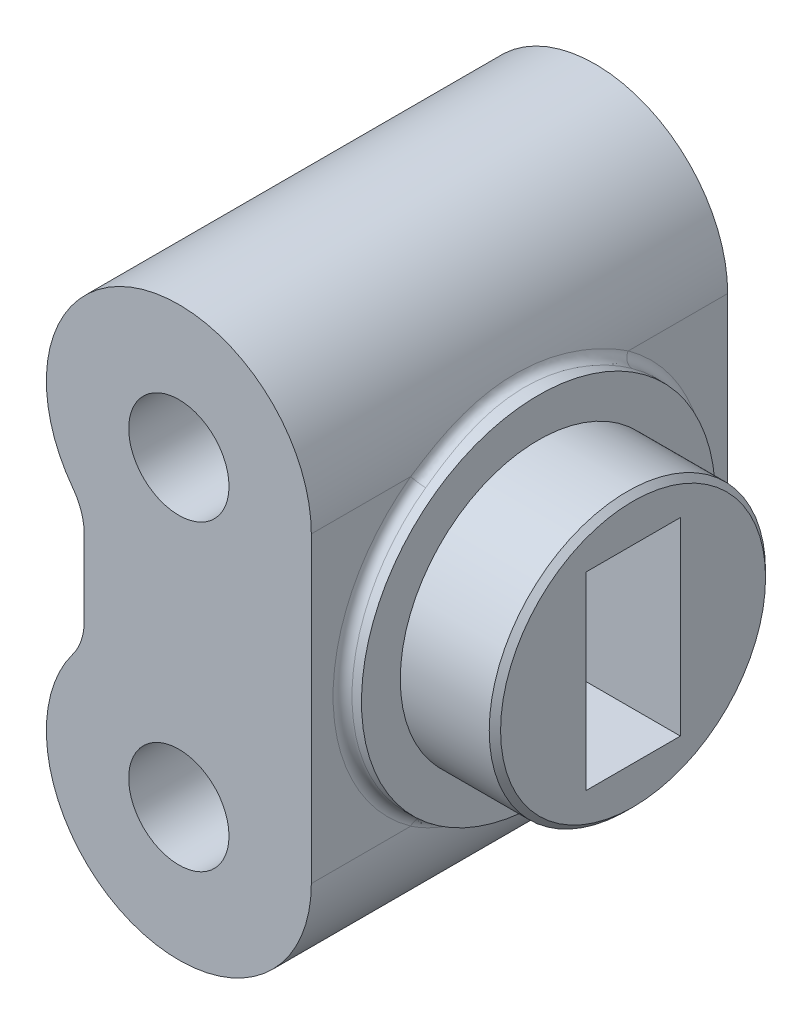
from build123d import *

# Parameters (mm, degrees)
SKETCH_1_R           = 2.65
EXTRUDE_1_DEPTH      = 22
CUT_EXTRUDE_1_DEPTH  = 23
SKETCH_3_R           = 9.35
EXTRUDE_2_DEPTH      = 1
EXTRUDE_2_DEPTH_BACK = 1
SKETCH_4_R           = 7.3
EXTRUDE_3_DEPTH      = 5
CHAMFER_1_SIZE       = 0.3
SKETCH_5_W           = 5
SKETCH_5_H           = 10
CUT_EXTRUDE_2_DEPTH  = 5
FILLET_1_R           = 0.5


with BuildPart() as part:
    # 草图1 → 凸台-拉伸1 (new body)
    with BuildSketch(Plane.XY):
        with BuildLine():
            Line((-7, 0), (-7, -16))
            ThreePointArc((-7, -16), (0, -23), (7, -16))
            Line((7, -16), (7, 0))
            ThreePointArc((7, 0), (0, 7), (-7, 0))
        make_face()
        Circle(SKETCH_1_R, mode=Mode.SUBTRACT)
        with Locations((0, -16)):
            Circle(SKETCH_1_R, mode=Mode.SUBTRACT)
    extrude(amount=EXTRUDE_1_DEPTH)

    # 草图2 → 切除-拉伸1 (cut, through all)
    with BuildSketch(Plane.XY.offset(22)):
        with BuildLine():
            Line((-5, -6), (-5, -10))
            ThreePointArc((-5, -10), (-5.153950106, -10.948683298), (-5.6, -11.8))
            ThreePointArc((-5.6, -11.8), (-6.640783086, -13.786405638), (-7, -16))
            Line((-7, -16), (-7, 0))
            ThreePointArc((-7, 0), (-6.640783086, -2.213594362), (-5.6, -4.2))
            ThreePointArc((-5.6, -4.2), (-5.153950106, -5.051316702), (-5, -6))
        make_face()
    extrude(amount=-CUT_EXTRUDE_1_DEPTH, mode=Mode.SUBTRACT)

    # 草图3 → 凸台-拉伸2 (add, two sides)
    with BuildSketch(Plane(origin=(7, 0, 0), x_dir=(0, 0, -1), z_dir=(1, 0, 0))) as extrude_2_sk:
        with Locations((-11, -8)):
            Circle(SKETCH_3_R)
    extrude(amount=EXTRUDE_2_DEPTH)
    extrude(extrude_2_sk.sketch, amount=-EXTRUDE_2_DEPTH_BACK)

    # 草图4 → 凸台-拉伸3 (add)
    with BuildSketch(Plane(origin=(8, 0, 0), x_dir=(0, 0, -1), z_dir=(1, 0, 0))):
        with Locations((-11, -8)):
            Circle(SKETCH_4_R)
    extrude(amount=EXTRUDE_3_DEPTH)

    # 倒角1
    chamfer_1_edges = [part.edges().sort_by_distance(p)[0] for p in [
        (13, -8, 18.3),
    ]]
    chamfer(chamfer_1_edges, length=CHAMFER_1_SIZE)

    # 草图5 → 切除-拉伸2 (cut)
    with BuildSketch(Plane(origin=(13, 0, 0), x_dir=(0, 0, -1), z_dir=(1, 0, 0))):
        with Locations((-11, -8)):
            Rectangle(SKETCH_5_W, SKETCH_5_H)
    extrude(amount=-CUT_EXTRUDE_2_DEPTH, mode=Mode.SUBTRACT)

    # 圆角1
    fillet_1_edges = [part.edges().sort_by_distance(p)[0] for p in [
        (7, -8, 20.35),
        (-7, -16, 11),
        (7, -3.408078049, 2.855262264),
        (6.868587919, 1.35, 11),
    ]]
    fillet(fillet_1_edges, radius=FILLET_1_R)


solid = part.part
